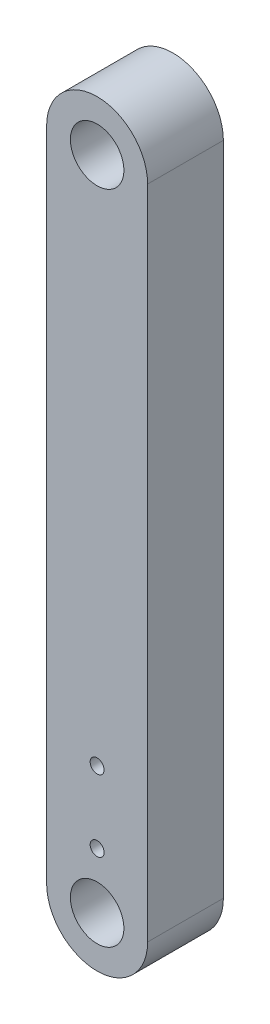
from build123d import *

# Parameters (mm, degrees)
SKETCH1_R           = 3.3655
BOSS_EXTRUDE1_DEPTH = 9.525
SKETCH2_R           = 0.877000024
CUT_EXTRUDE1_DEPTH  = 10.525


with BuildPart() as part:
    # Sketch1 → Boss-Extrude1 (new body)
    with BuildSketch(Plane.XY):
        with BuildLine():
            Line((-6.35, 0), (-6.35, 82.55))
            ThreePointArc((-6.35, 82.55), (0, 88.9), (6.35, 82.55))
            Line((6.35, 82.55), (6.35, 0))
            ThreePointArc((6.35, 0), (0, -6.35), (-6.35, 0))
        make_face()
        with Locations((0, 82.55)):
            Circle(SKETCH1_R, mode=Mode.SUBTRACT)
        Circle(SKETCH1_R, mode=Mode.SUBTRACT)
    extrude(amount=BOSS_EXTRUDE1_DEPTH)

    # Sketch2 → Cut-Extrude1 (cut, through all)
    with BuildSketch(Plane.XY.offset(9.525)):
        with Locations((0, 6.99999997)):
            Circle(SKETCH2_R)
        with Locations((0, 16.000000004)):
            Circle(SKETCH2_R)
    extrude(amount=-CUT_EXTRUDE1_DEPTH, mode=Mode.SUBTRACT)


solid = part.part
